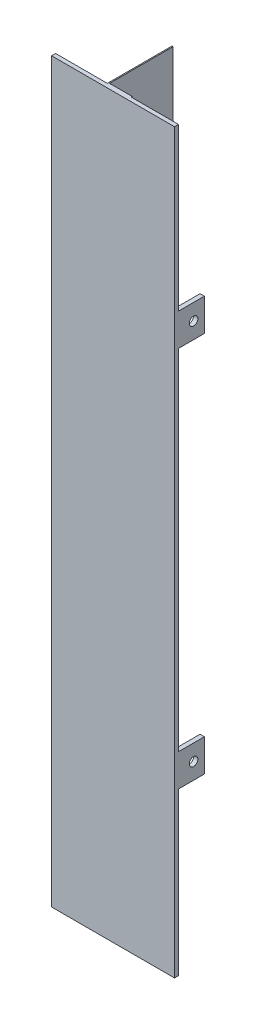
from build123d import *

# Parameters (mm, degrees)
DODANIE_WYCI_GNI_CIE1_DEPTH = 342
SZKIC3_W                    = 2
SZKIC3_H                    = 15
DODANIE_WYCI_GNI_CIE2_DEPTH = 12
SZKIC4_R                    = 2
WYTNIJ_WYCI_GNI_CIE1_DEPTH  = 10
SZKIC5_R                    = 2
WYTNIJ_WYCI_GNI_CIE2_DEPTH  = 10


with BuildPart() as part:
    # Szkic1 → Dodanie-wyciągnięcie1 (new body)
    with BuildSketch(Plane(origin=(0, 0, 0), x_dir=(1, 0, 0), z_dir=(0, 1, 0))):
        Polygon((0, 0), (0, 1.85), (24, 1.85), (24, 31.85), (24.5, 31.85), (24.5, 2.35), (35, 2.35), (35, 1.85), (57, 1.85), (57, 0), align=None)
    extrude(amount=DODANIE_WYCI_GNI_CIE1_DEPTH)

    # Szkic3 → Dodanie-wyciągnięcie2 (add)
    with BuildSketch(Plane(origin=(0, 0, -1.85), x_dir=(-1, 0, 0), z_dir=(0, 0, -1))):
        with Locations((-56, 82.5)):
            Rectangle(SZKIC3_W, SZKIC3_H)
        with Locations((-56, 259.5)):
            Rectangle(SZKIC3_W, SZKIC3_H)
        with Locations((-1, 82.5)):
            Rectangle(SZKIC3_W, SZKIC3_H)
        with Locations((-1, 259.5)):
            Rectangle(SZKIC3_W, SZKIC3_H)
    extrude(amount=DODANIE_WYCI_GNI_CIE2_DEPTH)

    # Szkic4 → Wytnij-wyciągnięcie1 (cut)
    with BuildSketch(Plane.ZY):
        with Locations((-8.85, 82.5)):
            Circle(SZKIC4_R)
        with Locations((-8.85, 259.5)):
            Circle(SZKIC4_R)
    extrude(amount=-WYTNIJ_WYCI_GNI_CIE1_DEPTH, mode=Mode.SUBTRACT)

    # Szkic5 → Wytnij-wyciągnięcie2 (cut)
    with BuildSketch(Plane(origin=(57, 0, 0), x_dir=(0, 0, -1), z_dir=(1, 0, 0))):
        with Locations((8.85, 259.5)):
            Circle(SZKIC5_R)
        with Locations((8.85, 82.5)):
            Circle(SZKIC5_R)
    extrude(amount=-WYTNIJ_WYCI_GNI_CIE2_DEPTH, mode=Mode.SUBTRACT)


solid = part.part
